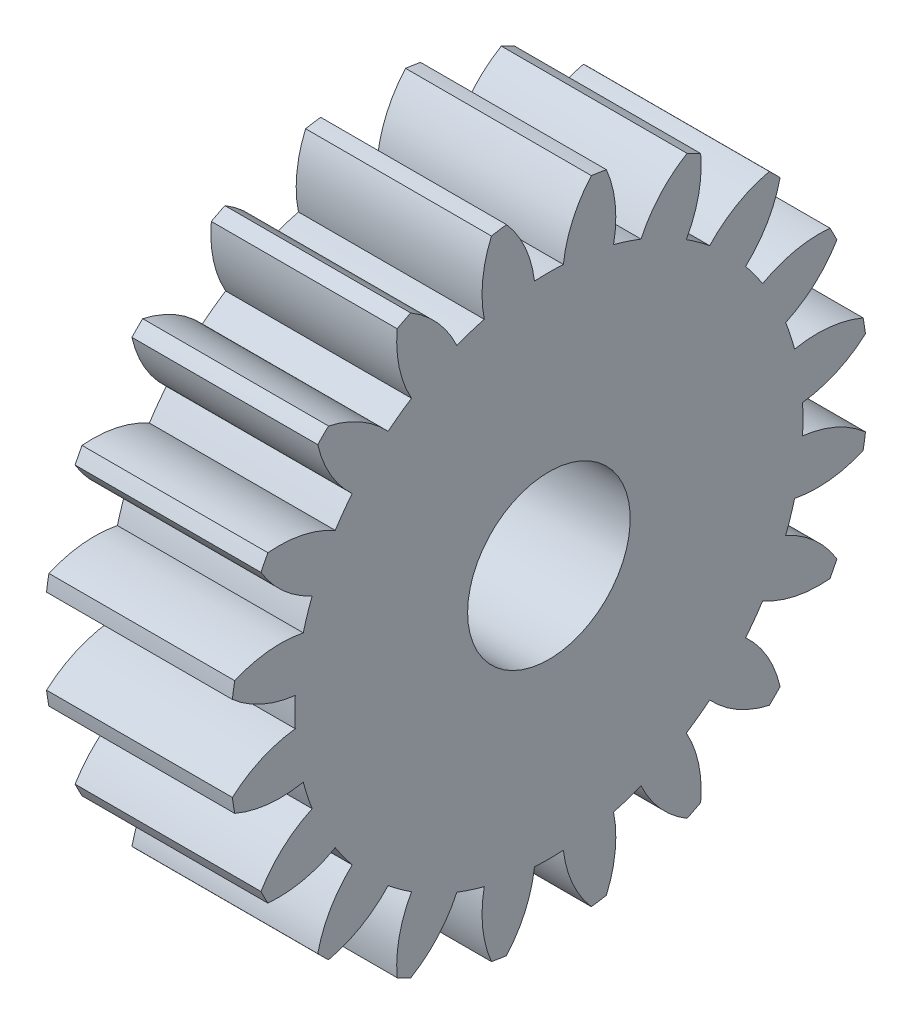
from build123d import *

# Parameters (mm, degrees)
BASPROSKE_W     = 8
BASPROSKE_H     = 13.75
TOOTHCUT_DEPTH  = 22.026768653
TEETHCUTS_COUNT = 20
TEETHCUTS_ANGLE = 342
BORSKE_R        = 3.5
BORE_DEPTH      = 50.0000508


with BuildPart() as part:
    # BasProSke → Base-Revolve (revolve)
    with BuildSketch(Plane(origin=(0, 0, 0), x_dir=(1, 0, 0), z_dir=(0, 1, 0)), mode=Mode.PRIVATE) as base_revolve_sk:
        with Locations((4, 6.875)):
            Rectangle(BASPROSKE_W, BASPROSKE_H)
    revolve(base_revolve_sk.sketch.rotate(Axis((-10, 0, 0), (1, 0, 0)), 180), axis=Axis((-10, 0, 0), (1, 0, 0)))

    # TooCutSke → ToothCut (cut, through all)
    with BuildSketch(Plane(origin=(0, 0, 0), x_dir=(0, 0, -1), z_dir=(1, 0, 0))):
        with BuildLine():
            ThreePointArc((0.62110296, 10.918848994), (0, 10.9365), (-0.62110296, 10.918848994))
            ThreePointArc((-0.62110296, 10.918848994), (-1.024517052, 12.378857135), (-1.846615859, 13.651067908))
            ThreePointArc((-1.846615859, 13.651067908), (0, 13.7754), (1.846615859, 13.651067908))
            ThreePointArc((1.846615859, 13.651067908), (1.024517052, 12.378857135), (0.62110296, 10.918848994))
        make_face()
    toothcut = extrude(amount=TOOTHCUT_DEPTH, mode=Mode.SUBTRACT)

    # TeethCuts: ToothCut ×20 about axis
    teethcuts_axis = Axis((-10, 0, 0), (1, 0, 0))
    for i in range(1, TEETHCUTS_COUNT):
        add(toothcut.rotate(teethcuts_axis, i * TEETHCUTS_ANGLE / (TEETHCUTS_COUNT - 1)), mode=Mode.SUBTRACT)

    # BorSke → Bore (cut, symmetric)
    with BuildSketch(Plane(origin=(0, 0, 0), x_dir=(0, 0, -1), z_dir=(1, 0, 0))):
        with Locations(Location((0, 0, 0), (0, 0, 180))):
            Circle(BORSKE_R)
    extrude(amount=BORE_DEPTH, both=True, mode=Mode.SUBTRACT)


solid = part.part
